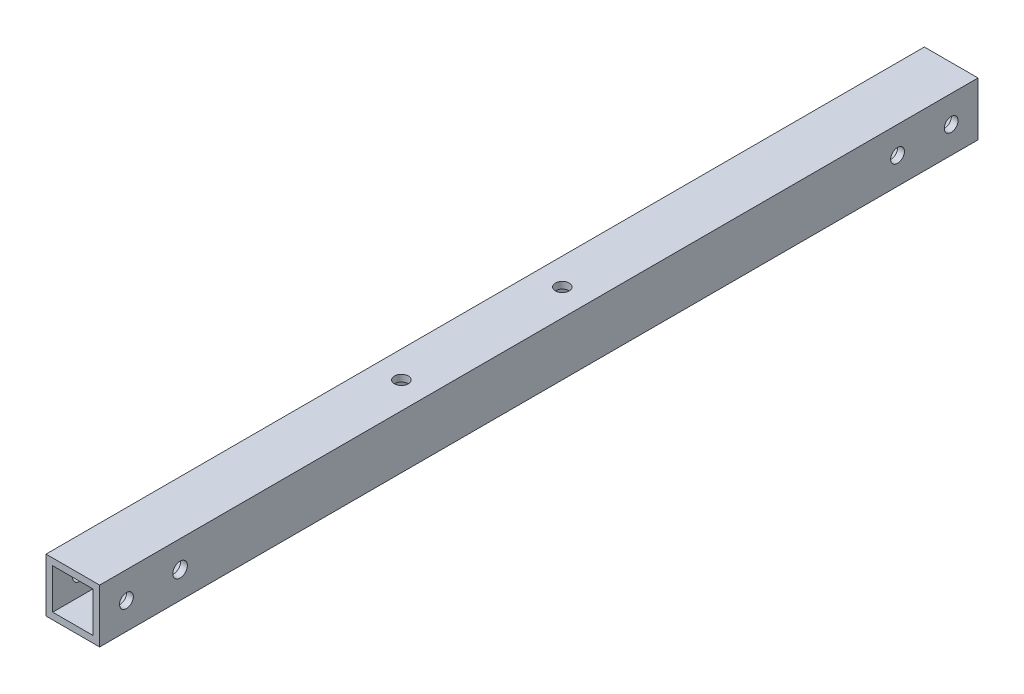
from build123d import *

# Parameters (mm, degrees)
SKETCH1_W                = 25.4
SKETCH1_H                = 25.4
SKETCH1_W_2              = 19.05
SKETCH1_H_2              = 19.05
BOSS_EXTRUDE1_DEPTH      = 415.925
F_0_257_DIAMETER_HOLE1_D = 6.5278
I_0_272_DIAMETER_HOLE1_D = 6.9088
F_0_257_DIAMETER_HOLE2_D = 6.5278


with BuildPart() as part:
    # Sketch1 → Boss-Extrude1 (new body)
    with BuildSketch(Plane.XY):
        Rectangle(SKETCH1_W, SKETCH1_H)
        Rectangle(SKETCH1_W_2, SKETCH1_H_2, mode=Mode.SUBTRACT)
    extrude(amount=BOSS_EXTRUDE1_DEPTH)

    # F (0.257) Diameter Hole1 (through all)
    with Locations(Plane(origin=(12.7, 0, 0), x_dir=(0, 0, -1), z_dir=(1, 0, 0))):
        with Locations((-403.225, 0), (-12.7, 0), (-38.1, 0)):
            Hole(F_0_257_DIAMETER_HOLE1_D / 2)

    # I (0.272) Diameter Hole1 (through all)
    with Locations(Plane(origin=(12.7, 0, 0), x_dir=(0, 0, -1), z_dir=(1, 0, 0))):
        with Locations((-377.825, 0)):
            Hole(I_0_272_DIAMETER_HOLE1_D / 2)

    # F (0.257) Diameter Hole2 (through all)
    with Locations(Plane(origin=(0, 12.7, 0), x_dir=(1, 0, 0), z_dir=(0, 1, 0))):
        with Locations((0, -184.15), (0, -260.35)):
            Hole(F_0_257_DIAMETER_HOLE2_D / 2)


solid = part.part
